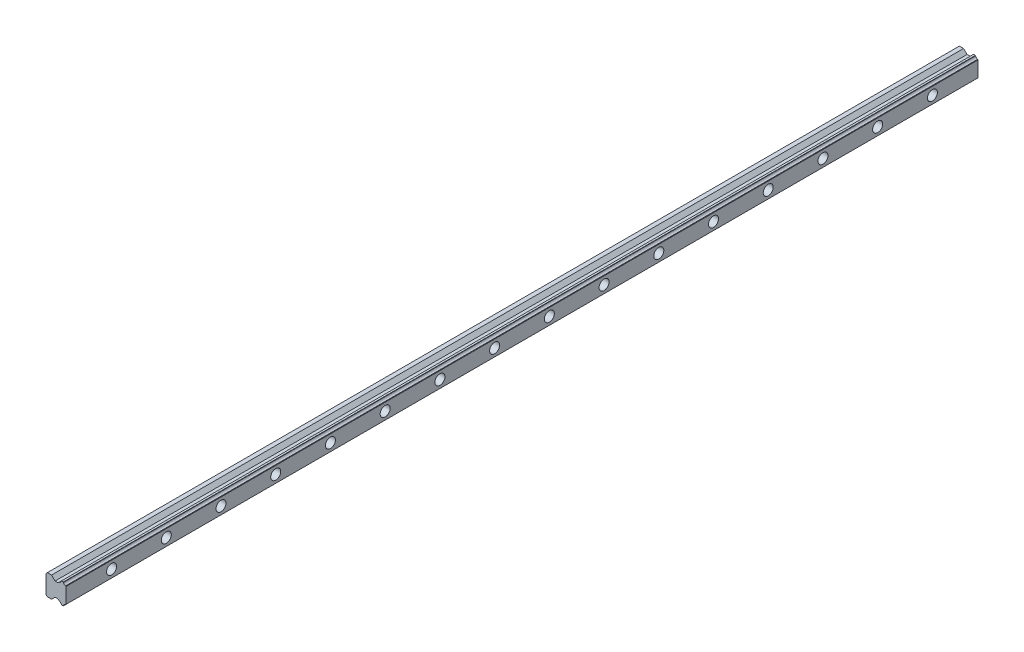
from build123d import *

# Parameters (mm, degrees)
RESSALTO_EXTRUS_O1_DEPTH = 1000
ESBO_O4_R                = 3.5
CORTE_EXTRUS_O1_DEPTH    = 22.900000388
ESBO_O5_R                = 5.5
CORTE_EXTRUS_O2_DEPTH    = 8.9


with BuildPart() as part:
    # Esboço2 → Ressalto-extrusão1 (new body)
    with BuildSketch(Plane.XY):
        with BuildLine():
            Line((-1.14927176, 21.393056679), (-1.14927176, 1.393056679))
            Line((-1.14927176, 1.393056679), (0.35072824, -0.106943321))
            Line((0.35072824, -0.106943321), (4.94937774, -0.106943321))
            Line((4.94937774, -0.106943321), (8.749377483, 3.693056422))
            Line((8.749377483, 3.693056422), (12.130866629, 3.693056422))
            Line((12.130866629, 3.693056422), (13.36057142, 2.463351631))
            ThreePointArc((13.36057142, 2.463351631), (14.896988246, 1.734969723), (15.625370154, 0.198552898))
            Line((15.625370154, 0.198552898), (15.830866097, -0.006942978))
            Line((15.830866097, -0.006942978), (17.859427097, -0.006942978))
            Line((17.859427097, -0.006942978), (18.077094898, 0.210724894))
            ThreePointArc((18.077094898, 0.210724894), (18.804225931, 1.734970575), (20.328471586, 2.462101662))
            Line((20.328471586, 2.462101662), (20.750728628, 2.884358639))
            Line((20.750728628, 2.884358639), (20.750728628, 19.901756343))
            Line((20.750728628, 19.901756343), (20.328471651, 20.324013385))
            ThreePointArc((20.328471651, 20.324013385), (18.804226447, 21.0511438), (18.077094898, 22.575388463))
            Line((18.077094898, 22.575388463), (17.859427097, 22.793056335))
            Line((17.859427097, 22.793056335), (15.830866097, 22.793056335))
            Line((15.830866097, 22.793056335), (15.625370154, 22.58756046))
            ThreePointArc((15.625370154, 22.58756046), (14.896988246, 21.051143635), (13.36057142, 20.322761727))
            Line((13.36057142, 20.322761727), (12.130866629, 19.093056935))
            Line((12.130866629, 19.093056935), (8.749377483, 19.093056935))
            Line((8.749377483, 19.093056935), (4.94937774, 22.893056679))
            Line((4.94937774, 22.893056679), (0.35072824, 22.893056679))
            Line((0.35072824, 22.893056679), (-1.14927176, 21.393056679))
        make_face()
    extrude(amount=RESSALTO_EXTRUS_O1_DEPTH)

    # Esboço4 → Corte-extrusão1 (cut, through all)
    with BuildSketch(Plane(origin=(20.750728628, 0, 0), x_dir=(0, 0, -1), z_dir=(1, 0, 0))):
        with Locations((-50, 11.393057491)):
            Circle(ESBO_O4_R)
        with Locations((-110, 11.393057491)):
            Circle(ESBO_O4_R)
        with Locations((-170, 11.393057491)):
            Circle(ESBO_O4_R)
        with Locations((-230, 11.393057491)):
            Circle(ESBO_O4_R)
        with Locations((-290, 11.393057491)):
            Circle(ESBO_O4_R)
        with Locations((-350, 11.393057491)):
            Circle(ESBO_O4_R)
        with Locations((-410, 11.393057491)):
            Circle(ESBO_O4_R)
        with Locations((-470, 11.393057491)):
            Circle(ESBO_O4_R)
        with Locations((-530, 11.393057491)):
            Circle(ESBO_O4_R)
        with Locations((-590, 11.393057491)):
            Circle(ESBO_O4_R)
        with Locations((-650, 11.393057491)):
            Circle(ESBO_O4_R)
        with Locations((-710, 11.393057491)):
            Circle(ESBO_O4_R)
        with Locations((-770, 11.393057491)):
            Circle(ESBO_O4_R)
        with Locations((-830, 11.393057491)):
            Circle(ESBO_O4_R)
        with Locations((-890, 11.393057491)):
            Circle(ESBO_O4_R)
        with Locations((-950, 11.393057491)):
            Circle(ESBO_O4_R)
    extrude(amount=-CORTE_EXTRUS_O1_DEPTH, mode=Mode.SUBTRACT)

    # Esboço5 → Corte-extrusão2 (cut)
    with BuildSketch(Plane(origin=(20.750728628, 0, 0), x_dir=(0, 0, -1), z_dir=(1, 0, 0))):
        with Locations((-50, 11.393057491)):
            Circle(ESBO_O5_R)
        with Locations((-110, 11.393057491)):
            Circle(ESBO_O5_R)
        with Locations((-170, 11.393057491)):
            Circle(ESBO_O5_R)
        with Locations((-230, 11.393057491)):
            Circle(ESBO_O5_R)
        with Locations((-290, 11.393057491)):
            Circle(ESBO_O5_R)
        with Locations((-350, 11.393057491)):
            Circle(ESBO_O5_R)
        with Locations((-410, 11.393057491)):
            Circle(ESBO_O5_R)
        with Locations((-470, 11.393057491)):
            Circle(ESBO_O5_R)
        with Locations((-530, 11.393057491)):
            Circle(ESBO_O5_R)
        with Locations((-590, 11.393057491)):
            Circle(ESBO_O5_R)
        with Locations((-650, 11.393057491)):
            Circle(ESBO_O5_R)
        with Locations((-710, 11.393057491)):
            Circle(ESBO_O5_R)
        with Locations((-770, 11.393057491)):
            Circle(ESBO_O5_R)
        with Locations((-830, 11.393057491)):
            Circle(ESBO_O5_R)
        with Locations((-890, 11.393057491)):
            Circle(ESBO_O5_R)
        with Locations((-950, 11.393057491)):
            Circle(ESBO_O5_R)
    extrude(amount=-CORTE_EXTRUS_O2_DEPTH, mode=Mode.SUBTRACT)


solid = part.part
